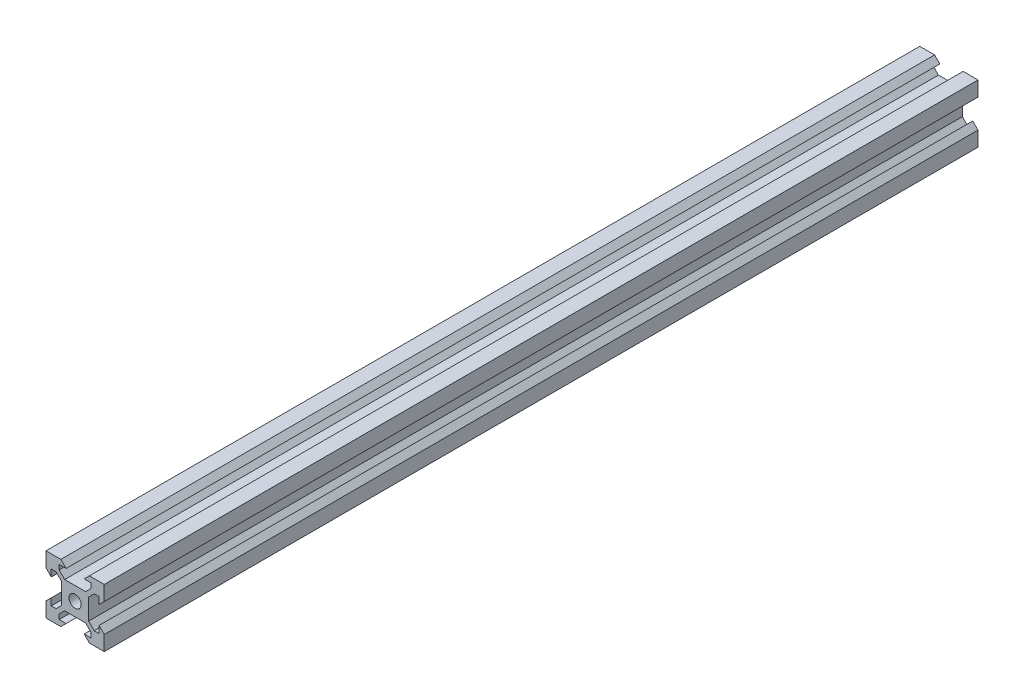
from build123d import *

# Parameters (mm, degrees)
SKETCH1_R           = 2.1
BOSS_EXTRUDE1_DEPTH = 150


with BuildPart() as part:
    # Sketch1 → Boss-Extrude1 (new body, symmetric)
    with BuildSketch(Plane.XY):
        Polygon((5.499339828, 6.56), (3.59, 4.650660172), (-3.59, 4.650660172), (-5.499339828, 6.56), (-5.499339828, 8.2), (-3.1, 8.2), (-4.9, 10), (-10, 10), (-10, 4.9), (-8.2, 3.1), (-8.2, 5.499339828), (-6.56, 5.499339828), (-4.650660172, 3.59), (-4.650660172, -3.59), (-6.56, -5.499339828), (-8.2, -5.499339828), (-8.2, -3.1), (-10, -4.9), (-10, -10), (-4.9, -10), (-3.1, -8.2), (-5.499339828, -8.2), (-5.499339828, -6.56), (-3.59, -4.650660172), (3.59, -4.650660172), (5.499339828, -6.56), (5.499339828, -8.2), (3.1, -8.2), (4.9, -10), (10, -10), (10, -4.9), (8.2, -3.1), (8.2, -5.499339828), (6.56, -5.499339828), (4.650660172, -3.59), (4.650660172, 3.59), (6.56, 5.499339828), (8.2, 5.499339828), (8.2, 3.1), (10, 4.9), (10, 10), (4.9, 10), (3.1, 8.2), (5.499339828, 8.2), align=None)
        Circle(SKETCH1_R, mode=Mode.SUBTRACT)
    extrude(amount=BOSS_EXTRUDE1_DEPTH, both=True)


solid = part.part
